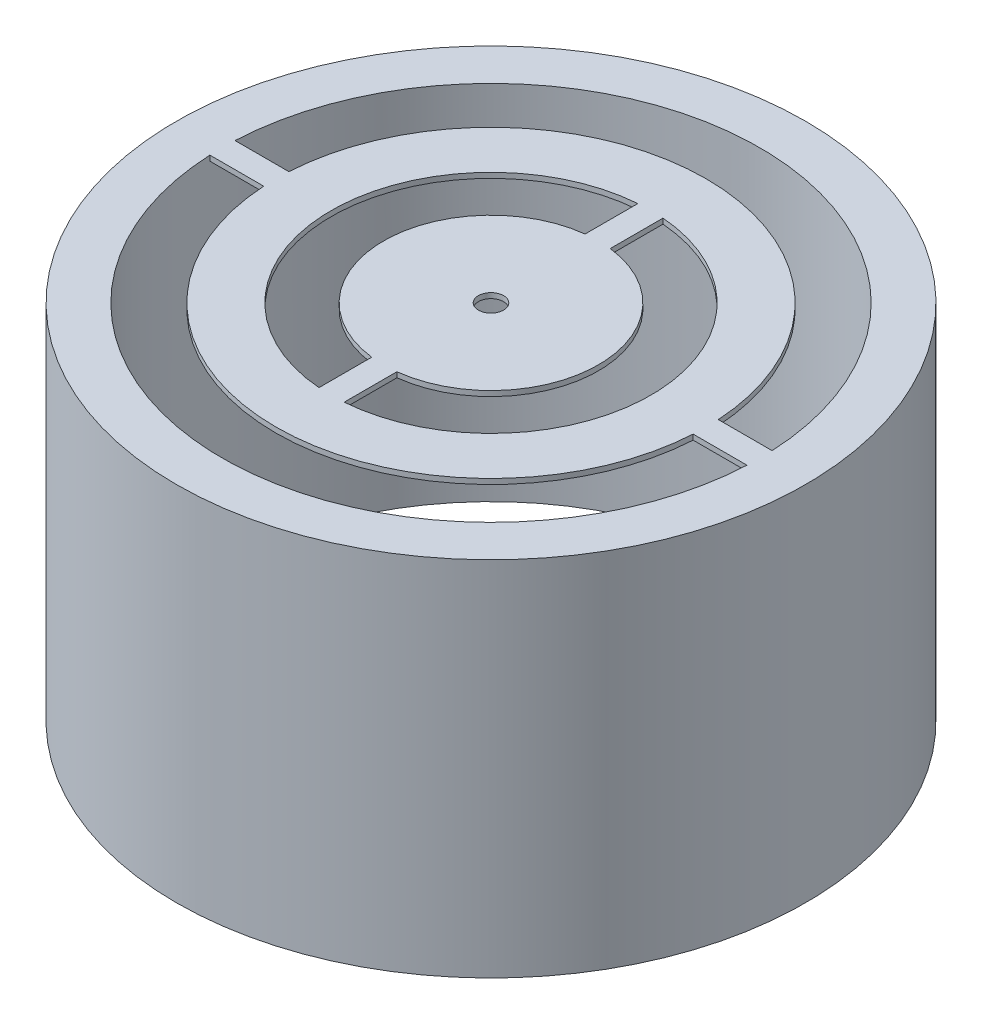
from build123d import *

# Parameters (mm, degrees)
SKETCH1_R           = 15
SKETCH1_R_2         = 0.6
BOSS_EXTRUDE1_DEPTH = 0.25
SKETCH2_R           = 15
SKETCH2_R_2         = 12.815737343
BOSS_EXTRUDE2_DEPTH = 17.268


with BuildPart() as part:
    # Sketch1 → Boss-Extrude1 (new body)
    with BuildSketch(Plane(origin=(0, 0, 0), x_dir=(1, 0, 0), z_dir=(0, 1, 0))):
        Circle(SKETCH1_R)
        Circle(SKETCH1_R_2, mode=Mode.SUBTRACT)
        with BuildLine():
            Line((-12.801684406, 0.6), (-10.235182592, 0.6))
            ThreePointArc((-10.235182592, 0.6), (0, 10.252753907), (10.235182592, 0.6))
            Line((10.235182592, 0.6), (12.801684406, 0.6))
            ThreePointArc((12.801684406, 0.6), (0, 12.815737343), (-12.801684406, 0.6))
        make_face(mode=Mode.SUBTRACT)
        with BuildLine():
            Line((-0.6, 7.600213812), (-0.6, 5.084960781))
            ThreePointArc((-0.6, 5.084960781), (-5.120236922, 0), (-0.6, -5.084960781))
            Line((-0.6, -5.084960781), (-0.6, -7.600213812))
            ThreePointArc((-0.6, -7.600213812), (-7.623860569, 0), (-0.6, 7.600213812))
        make_face(mode=Mode.SUBTRACT)
        with BuildLine():
            Line((0.6, 5.084960781), (0.6, 7.600213812))
            ThreePointArc((0.6, 7.600213812), (7.623860569, 0), (0.6, -7.600213812))
            Line((0.6, -7.600213812), (0.6, -5.084960781))
            ThreePointArc((0.6, -5.084960781), (5.120236922, 0), (0.6, 5.084960781))
        make_face(mode=Mode.SUBTRACT)
        with BuildLine():
            Line((-12.801684406, -0.6), (-10.235182592, -0.6))
            ThreePointArc((-10.235182592, -0.6), (0, -10.252753907), (10.235182592, -0.6))
            Line((10.235182592, -0.6), (12.801684406, -0.6))
            ThreePointArc((12.801684406, -0.6), (0, -12.815737343), (-12.801684406, -0.6))
        make_face(mode=Mode.SUBTRACT)
    extrude(amount=BOSS_EXTRUDE1_DEPTH)

    # Sketch2 → Boss-Extrude2 (add)
    with BuildSketch(Plane(origin=(0, 0.25, 0), x_dir=(1, 0, 0), z_dir=(0, 1, 0))):
        Circle(SKETCH2_R)
        Circle(SKETCH2_R_2, mode=Mode.SUBTRACT)
    extrude(amount=-BOSS_EXTRUDE2_DEPTH)


solid = part.part
